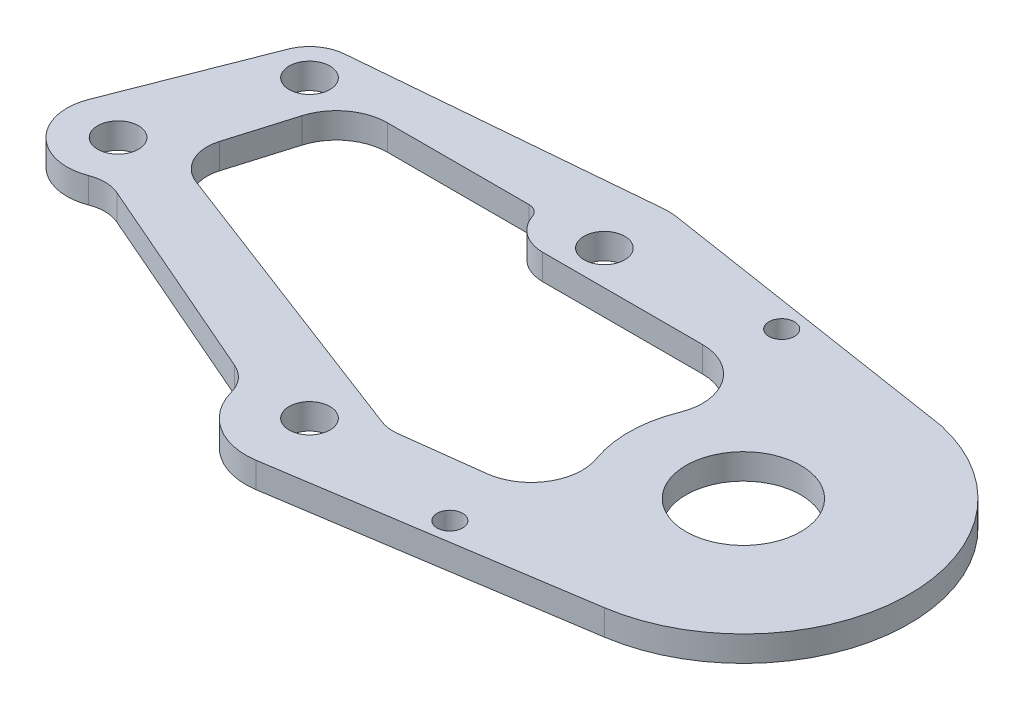
from build123d import *

# Parameters (mm, degrees)
SKETCH1_R           = 1.6
SKETCH1_R_2         = 1
SKETCH1_R_3         = 5.5
SKETCH1_R_4         = 4.5
BOSS_EXTRUDE2_DEPTH = 2
SKETCH2_R           = 1
BOSS_EXTRUDE3_DEPTH = 2
SKETCH3_R           = 1
CUT_EXTRUDE1_DEPTH  = 103
CUT_EXTRUDE2_DEPTH  = 10
BOSS_EXTRUDE4_DEPTH = 2
FILLET1_R           = 3
CUT_EXTRUDE3_DEPTH  = 10
CUT_EXTRUDE4_DEPTH  = 10
BOSS_EXTRUDE5_DEPTH = 2
CUT_EXTRUDE5_DEPTH  = 10
CUT_EXTRUDE9_DEPTH  = 10
FILLET3_R           = 4
CUT_EXTRUDE10_DEPTH = 10
FILLET4_R           = 4
FILLET6_R           = 1
FILLET7_R           = 3
SKETCH13_R          = 1.6
SKETCH13_R_2        = 1
SKETCH13_R_3        = 4.5
BOSS_EXTRUDE7_DEPTH = 2
FILLET8_R           = 3


with BuildPart() as part:
    # Sketch1 → Boss-Extrude2 (new body)
    with BuildSketch(Plane(origin=(0, 0, 0), x_dir=(1, 0, 0), z_dir=(0, 1, 0))):
        with BuildLine():
            Line((12.313589515, -16.493996637), (35.979225245, -12.848450001))
            ThreePointArc((35.979225245, -12.848450001), (46.993067566, -0.424494085), (36.813648041, 12.691862933))
            Line((36.813648041, 12.691862933), (35.165189196, 12.947676785))
            Line((35.165189196, 12.947676785), (12.319067304, 16.493021261))
            ThreePointArc((12.319067304, 16.493021261), (11.720527595, 16.549330191), (11.119556233, 16.533395936))
            Line((11.119556233, 16.533395936), (-11.812019178, 14.541098507))
            ThreePointArc((-11.812019178, 14.541098507), (-13.247239988, 14.027709898), (-14.244912332, 12.87528787))
            Line((-14.244912332, 12.87528787), (-19.487592157, 2.204884721))
            ThreePointArc((-19.487592157, 2.204884721), (-19.693653105, -1.723258696), (-16.994761113, -4.584858569))
            Line((-16.994761113, -4.584858569), (9.557587922, -16.137143667))
            ThreePointArc((9.557587922, -16.137143667), (10.910298182, -16.51089082), (12.313589515, -16.493996637))
        make_face()
        with Locations((11.552349036, -11.552285098)):
            Circle(SKETCH1_R, mode=Mode.SUBTRACT)
        with Locations((25, -11)):
            Circle(SKETCH1_R_2, mode=Mode.SUBTRACT)
        with Locations((-15, 0)):
            Circle(SKETCH1_R, mode=Mode.SUBTRACT)
        Circle(SKETCH1_R_3, mode=Mode.SUBTRACT)
        with Locations((-11.552357038, 11.552357038)):
            Circle(SKETCH1_R, mode=Mode.SUBTRACT)
        with Locations((11.552326466, 11.552160153)):
            Circle(SKETCH1_R, mode=Mode.SUBTRACT)
        with Locations((14, 0)):
            Circle(SKETCH1_R_4, mode=Mode.SUBTRACT)
        with Locations((34, 0)):
            Circle(SKETCH1_R_4, mode=Mode.SUBTRACT)
        with Locations((25, 11)):
            Circle(SKETCH1_R_2, mode=Mode.SUBTRACT)
    extrude(amount=BOSS_EXTRUDE2_DEPTH)

    # Sketch2 → Boss-Extrude3 (add)
    with BuildSketch(Plane(origin=(0, 2, 0), x_dir=(1, 0, 0), z_dir=(0, 1, 0))):
        with Locations((25, 11)):
            Circle(SKETCH2_R)
        with Locations((25, -11)):
            Circle(SKETCH2_R)
    extrude(amount=-BOSS_EXTRUDE3_DEPTH)

    # Sketch3 → Cut-Extrude1 (cut)
    with BuildSketch(Plane(origin=(0, 2, 0), x_dir=(1, 0, 0), z_dir=(0, 1, 0))):
        with Locations((24, 13)):
            Circle(SKETCH3_R)
        with Locations((24, -13)):
            Circle(SKETCH3_R)
    extrude(amount=-CUT_EXTRUDE1_DEPTH, mode=Mode.SUBTRACT)

    # Sketch4 → Cut-Extrude2 (cut)
    with BuildSketch(Plane(origin=(0, 2, 0), x_dir=(1, 0, 0), z_dir=(0, 1, 0))):
        with BuildLine():
            Line((-11.556207856, 1.04895048), (-9.269369924, 8.711683705))
            Line((-9.269369924, 8.711683705), (11.51784634, 8.478494442))
            Line((11.51784634, 8.478494442), (14.72101257, 8.44256159))
            ThreePointArc((14.72101257, 8.44256159), (23.806986873, -0.105659112), (15.258766171, -9.191633415))
            Line((15.258766171, -9.191633415), (11.546390573, -7.773884745))
            Line((11.546390573, -7.773884745), (-11.556207856, 1.04895048))
        make_face()
    extrude(amount=-CUT_EXTRUDE2_DEPTH, mode=Mode.SUBTRACT)

    # Sketch5 → Boss-Extrude4 (add)
    with BuildSketch(Plane(origin=(0, 2, 0), x_dir=(1, 0, 0), z_dir=(0, 1, 0))):
        Polygon((-5.337802217, -1.325845952), (3.09520559, -4.546394435), (3.755970184, -8.105851045), (-7.77052306, -5.643881614), align=None)
    extrude(amount=-BOSS_EXTRUDE4_DEPTH)

    # Fillet1
    fillet1_edges = [part.edges().sort_by_distance(p)[0] for p in [
        (14.72101257, 1, -8.44256159),
        (-11.556207856, 1, -1.04895048),
        (-9.269369924, 1, -8.711683705),
        (15.258766171, 1, 9.191633415),
    ]]
    fillet(fillet1_edges, radius=FILLET1_R)

    # Sketch6 → Cut-Extrude3 (cut)
    with BuildSketch(Plane(origin=(0, 2, 0), x_dir=(1, 0, 0), z_dir=(0, 1, 0))):
        with BuildLine():
            Line((-10.415141431, -1.994761113), (6.967490467, -9.557523985))
            ThreePointArc((6.967490467, -9.557523985), (7.370614613, -14.293288056), (11.552349036, -16.552285098))
            Line((11.552349036, -16.552285098), (4.640159697, -19.625925194))
            Line((4.640159697, -19.625925194), (-19.442024068, -14.318556871))
            Line((-19.442024068, -14.318556871), (-16.994761113, -4.584858569))
            ThreePointArc((-16.994761113, -4.584858569), (-13.168524525, -4.652493695), (-10.415141431, -1.994761113))
        make_face()
    extrude(amount=-CUT_EXTRUDE3_DEPTH, mode=Mode.SUBTRACT)

    # Sketch7 → Cut-Extrude4 (cut)
    with BuildSketch(Plane(origin=(0, 2, 0), x_dir=(1, 0, 0), z_dir=(0, 1, 0))):
        with BuildLine():
            Line((-19.487592157, 2.204884721), (-14.360758579, 12.639506513))
            Line((-14.360758579, 12.639506513), (-40.027877899, 1.746555748))
            Line((-40.027877899, 1.746555748), (-13.686394089, -14.892557088))
            Line((-13.686394089, -14.892557088), (-5.537805094, -4.116772232))
            Line((-5.537805094, -4.116772232), (-10.415141431, -1.994761113))
            ThreePointArc((-10.415141431, -1.994761113), (-17.100386029, -4.537441849), (-19.487592157, 2.204884721))
        make_face()
        with BuildLine():
            Line((-18.724859342, 1.457883014), (-14.346001544, 12.645769298))
            Line((-14.346001544, 12.645769298), (-14.360758579, 12.639506513))
            Line((-14.360758579, 12.639506513), (-19.487592157, 2.204884721))
            ThreePointArc((-19.487592157, 2.204884721), (-17.100386029, -4.537441849), (-10.415141431, -1.994761113))
            Line((-10.415141431, -1.994761113), (-11.332113145, -1.595808891))
            ThreePointArc((-11.332113145, -1.595808891), (-16.527111662, -3.697016361), (-18.724859342, 1.457883014))
        make_face()
    extrude(amount=-CUT_EXTRUDE4_DEPTH, mode=Mode.SUBTRACT)

    # Sketch8 → Boss-Extrude5 (add)
    with BuildSketch(Plane(origin=(0, 2, 0), x_dir=(1, 0, 0), z_dir=(0, 1, 0))):
        Polygon((-2.581263562, -6.493638152), (8.323551355, -11.238059471), (9.15275877, -8.13729454), (-12.005428352, 0), (-12.793973249, -2.050335084), align=None)
    extrude(amount=-BOSS_EXTRUDE5_DEPTH)

    # Sketch9 → Cut-Extrude5 (cut)
    with BuildSketch(Plane(origin=(0, 2, 0), x_dir=(1, 0, 0), z_dir=(0, 1, 0))):
        with BuildLine():
            Line((3.827614939, 8.564762818), (30.440563146, 8.266220979))
            ThreePointArc((30.440563146, 8.266220979), (25.034594613, 0.788356673), (29.052589856, -7.518186807))
            Line((29.052589856, -7.518186807), (16.076287148, -9.128577435))
            Line((16.076287148, -9.128577435), (3.827614939, 8.564762818))
        make_face()
    extrude(amount=-CUT_EXTRUDE5_DEPTH, mode=Mode.SUBTRACT)

    # Sketch10 → Cut-Extrude9 (cut)
    with BuildSketch(Plane(origin=(0, 2, 0), x_dir=(1, 0, 0), z_dir=(0, 1, 0))):
        with BuildLine():
            ThreePointArc((-7.00779509, 8.686313546), (-8.820444577, 8.102111249), (-9.916159809, 6.544421096))
            Line((-9.916159809, 6.544421096), (25.022400978, -0.634598928))
            ThreePointArc((25.022400978, -0.634598928), (26.312317261, 4.679693805), (30.440563146, 8.266220979))
            Line((30.440563146, 8.266220979), (22.948527848, 8.350266008))
            Line((22.948527848, 8.350266008), (15.45649255, 8.434311037))
            ThreePointArc((15.45649255, 8.434311037), (15.11388418, 8.44578882), (14.771088556, 8.443946344))
            ThreePointArc((14.771088556, 8.443946344), (14.717060069, 8.443092594), (14.663024969, 8.44321209))
            Line((14.663024969, 8.44321209), (-7.00779509, 8.686313546))
        make_face()
        with BuildLine():
            Line((-9.442365056, 8.850266008), (-9.916159809, 6.544421096))
            ThreePointArc((-9.916159809, 6.544421096), (-8.820444577, 8.102111249), (-7.00779509, 8.686313546))
            Line((-7.00779509, 8.686313546), (14.663024969, 8.44321209))
            ThreePointArc((14.663024969, 8.44321209), (14.717060069, 8.443092594), (14.771088556, 8.443946344))
            ThreePointArc((14.771088556, 8.443946344), (15.11388418, 8.44578882), (15.45649255, 8.434311037))
            Line((15.45649255, 8.434311037), (22.948527848, 8.350266008))
            Line((22.948527848, 8.350266008), (22.948527848, 8.850266008))
            Line((22.948527848, 8.850266008), (-9.442365056, 8.850266008))
        make_face()
        with BuildLine():
            Line((22.948527848, 8.350266008), (30.440563146, 8.266220979))
            ThreePointArc((30.440563146, 8.266220979), (31.386481977, 8.612172986), (32.365132548, 8.850266008))
            Line((32.365132548, 8.850266008), (22.948527848, 8.850266008))
            Line((22.948527848, 8.850266008), (22.948527848, 8.350266008))
        make_face()
    extrude(amount=-CUT_EXTRUDE9_DEPTH, mode=Mode.SUBTRACT)

    # Fillet3
    fillet3_edges = [part.edges().sort_by_distance(p)[0] for p in [
        (-9.442365056, 1, -8.850266008),
        (32.365132548, 1, -8.850266008),
        (29.052589856, 1, 7.518186807),
    ]]
    fillet(fillet3_edges, radius=FILLET3_R)

    # Sketch11 → Cut-Extrude10 (cut)
    with BuildSketch(Plane(origin=(0, 2, 0), x_dir=(1, 0, 0), z_dir=(0, 1, 0))):
        with BuildLine():
            Line((-8.421668575, 11.552160153), (-10.08037838, 5.994157747))
            ThreePointArc((-10.08037838, 5.994157747), (-8.637451976, 8.057723487), (-6.247427599, 8.850266008))
            Line((-6.247427599, 8.850266008), (7.345217242, 8.850266008))
            ThreePointArc((7.345217242, 8.850266008), (6.754642331, 10.14424434), (6.552326466, 11.552160153))
            Line((6.552326466, 11.552160153), (-8.421668575, 11.552160153))
        make_face()
    extrude(amount=-CUT_EXTRUDE10_DEPTH, mode=Mode.SUBTRACT)

    # Fillet4
    fillet4_edges = [part.edges().sort_by_distance(p)[0] for p in [
        (-8.421668575, 1, -11.552160153),
    ]]
    fillet(fillet4_edges, radius=FILLET4_R)

    # Fillet6
    fillet6_edges = [part.edges().sort_by_distance(p)[0] for p in [
        (6.552326466, 1, -11.552160153),
    ]]
    fillet(fillet6_edges, radius=FILLET6_R)

    # Fillet7
    fillet7_edges = [part.edges().sort_by_distance(p)[0] for p in [
        (7.345217242, 1, -8.850266008),
    ]]
    fillet(fillet7_edges, radius=FILLET7_R)

    # Sketch13 → Boss-Extrude7 (add)
    with BuildSketch(Plane(origin=(0, 2, 0), x_dir=(1, 0, 0), z_dir=(0, 1, 0))):
        with BuildLine():
            Line((-2.992134647, -7.405424257), (-2.593182424, -6.488452543))
            Line((-2.593182424, -6.488452543), (-11.847536046, -2.462107028))
            ThreePointArc((-11.847536046, -2.462107028), (-12.208910636, -2.865278374), (-12.62142125, -3.215954467))
            Line((-12.62142125, -3.215954467), (-2.992134647, -7.405424257))
        make_face()
        with BuildLine():
            Line((6.661171198, -10.514798057), (-2.593182424, -6.488452543))
            Line((-2.593182424, -6.488452543), (-2.992134647, -7.405424257))
            Line((-2.992134647, -7.405424257), (6.552352302, -11.557999767))
            ThreePointArc((6.552352302, -11.557999767), (6.579331737, -11.033537621), (6.661171198, -10.514798057))
        make_face()
        with BuildLine():
            Line((7.960909986, -12.17082916), (6.552352302, -11.557999767))
            ThreePointArc((6.552352302, -11.557999767), (8.299230544, -15.349286557), (12.313589515, -16.493996637))
            Line((12.313589515, -16.493996637), (35.979225245, -12.848450001))
            ThreePointArc((35.979225245, -12.848450001), (46.993067566, -0.424494085), (36.813648041, 12.691862933))
            Line((36.813648041, 12.691862933), (12.319067304, 16.493021261))
            ThreePointArc((12.319067304, 16.493021261), (11.720527595, 16.549330191), (11.119556233, 16.533395936))
            Line((11.119556233, 16.533395936), (-11.812019178, 14.541098507))
            ThreePointArc((-11.812019178, 14.541098507), (-13.247239988, 14.027709898), (-14.244912332, 12.87528787))
            Line((-14.244912332, 12.87528787), (-14.360758579, 12.639506513))
            Line((-14.360758579, 12.639506513), (-14.346001544, 12.645769298))
            Line((-14.346001544, 12.645769298), (-18.724859342, 1.457883014))
            ThreePointArc((-18.724859342, 1.457883014), (-17.431934838, -3.175798001), (-12.62142125, -3.215954467))
            Line((-12.62142125, -3.215954467), (-13.921939677, -2.650130342))
            Line((-13.921939677, -2.650130342), (-12.211113783, -0.329635092))
            Line((-12.211113783, -0.329635092), (7.960909986, -9.788126708))
            Line((7.960909986, -9.788126708), (7.960909986, -12.17082916))
        make_face()
        with Locations((11.552349036, -11.552285098)):
            Circle(SKETCH13_R, mode=Mode.SUBTRACT)
        with Locations((24, -13)):
            Circle(SKETCH13_R_2, mode=Mode.SUBTRACT)
        with Locations((-15, 0)):
            Circle(SKETCH13_R, mode=Mode.SUBTRACT)
        with BuildLine():
            Line((-5.441084244, 11.552160153), (5.636246683, 11.552160153))
            ThreePointArc((5.636246683, 11.552160153), (6.217397927, 11.365955725), (6.5821233, 10.876686617))
            ThreePointArc((6.5821233, 10.876686617), (7.676299419, 9.408879294), (9.419753151, 8.850266008))
            Line((9.419753151, 8.850266008), (21.938701577, 8.850266008))
            ThreePointArc((21.938701577, 8.850266008), (25.253030933, 7.0897349), (25.649870322, 3.357876467))
            ThreePointArc((25.649870322, 3.357876467), (25.001600498, 0.169724478), (25.529184516, -3.04060603))
            ThreePointArc((25.529184516, -3.04060603), (25.171651417, -6.487334994), (22.257008224, -8.361534964))
            Line((22.257008224, -8.361534964), (16.076287148, -9.128577435))
            ThreePointArc((16.076287148, -9.128577435), (15.345692081, -9.129601903), (14.636514373, -8.953996722))
            Line((14.636514373, -8.953996722), (-8.955748715, 0.055840437))
            ThreePointArc((-8.955748715, 0.055840437), (-10.5762844, 1.53199573), (-10.760161968, 3.716339886))
            Line((-10.760161968, 3.716339886), (-9.274035024, 8.696051893))
            ThreePointArc((-9.274035024, 8.696051893), (-7.83110862, 10.759617632), (-5.441084244, 11.552160153))
        make_face(mode=Mode.SUBTRACT)
        with Locations((-11.552357038, 11.552357038)):
            Circle(SKETCH13_R, mode=Mode.SUBTRACT)
        with Locations((11.552326466, 11.552160153)):
            Circle(SKETCH13_R, mode=Mode.SUBTRACT)
        with Locations((34, 0)):
            Circle(SKETCH13_R_3, mode=Mode.SUBTRACT)
        with Locations((24, 13)):
            Circle(SKETCH13_R_2, mode=Mode.SUBTRACT)
    extrude(amount=-BOSS_EXTRUDE7_DEPTH)

    # Fillet8
    fillet8_edges = [part.edges().sort_by_distance(p)[0] for p in [
        (-12.62142125, 1, 3.215954467),
        (6.552352302, 1, 11.557999767),
    ]]
    fillet(fillet8_edges, radius=FILLET8_R)


solid = part.part
